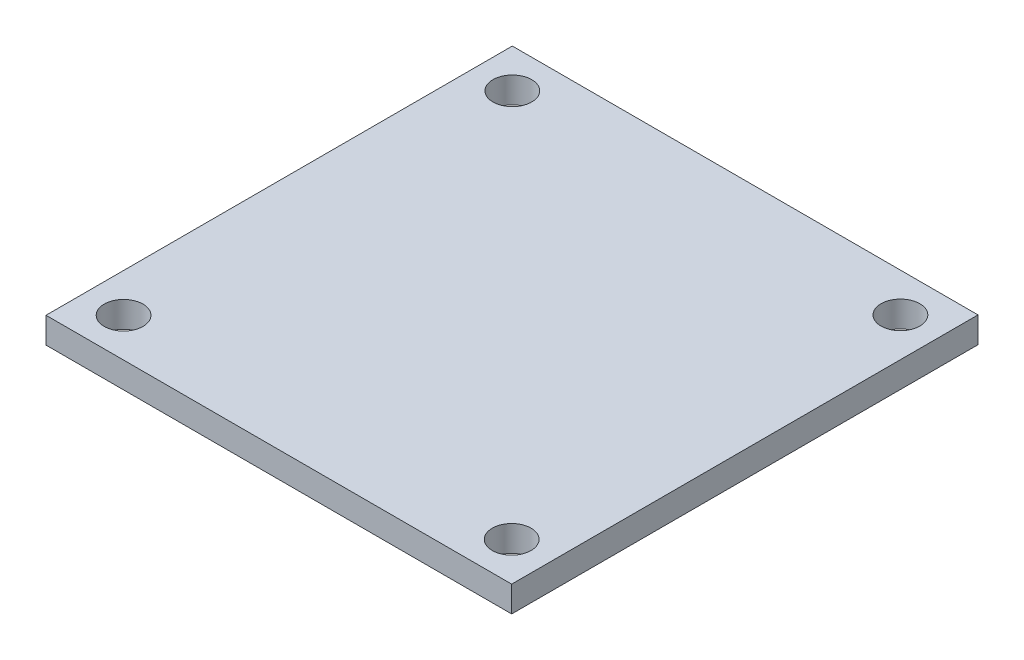
from build123d import *

# Parameters (mm, degrees)
SKETCH1_W           = 36.0172
SKETCH1_H           = 36.068
SKETCH1_R           = 1.5
BOSS_EXTRUDE1_DEPTH = 2


with BuildPart() as part:
    # Sketch1 → Boss-Extrude1 (new body)
    with BuildSketch(Plane(origin=(0, 0, 0), x_dir=(1, 0, 0), z_dir=(0, 1, 0))):
        Rectangle(SKETCH1_W, SKETCH1_H)
        with Locations((-15.0086, 15.034)):
            Circle(SKETCH1_R, mode=Mode.SUBTRACT)
        with Locations((15.0086, 15.034)):
            Circle(SKETCH1_R, mode=Mode.SUBTRACT)
        with Locations((-15.0086, -15.034)):
            Circle(SKETCH1_R, mode=Mode.SUBTRACT)
        with Locations((15.0086, -15.034)):
            Circle(SKETCH1_R, mode=Mode.SUBTRACT)
    extrude(amount=BOSS_EXTRUDE1_DEPTH)


solid = part.part
